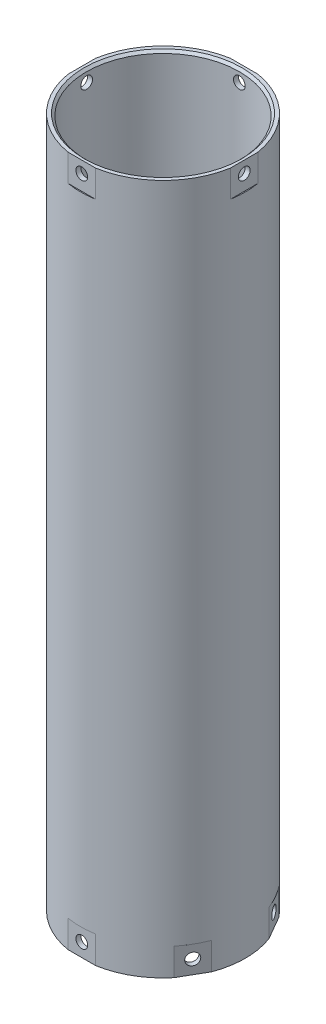
from build123d import *

# Parameters (mm, degrees)
F_1_4_0_25_DIAMETER_HOLE1_REACH  = 380.534
F_1_4_0_25_DIAMETER_HOLE1_BORE_R = 3.175
CIRPATTERN2_COUNT                = 4
CHAMFER1_SIZE                    = 1.27
CIRPATTERN1_COUNT                = 6
SKETCH7_W                        = 14.732
SKETCH7_H                        = 14.732
CUT_EXTRUDE1_DEPTH               = 0.635
SKETCH8_W                        = 16.51
SKETCH8_H                        = 16.51
CUT_EXTRUDE2_DEPTH               = 0.635
CIRPATTERN4_COUNT                = 6
CIRPATTERN5_COUNT                = 4


with BuildPart() as part:
    # Sketch2 → Revolve1 (revolve)
    with BuildSketch(Plane.XY, mode=Mode.PRIVATE) as revolve1_sk:
        Polygon((41.275, 0), (44.45, 0), (44.45, 372.618), (41.275, 372.618), (41.275, 186.309), align=None)
    revolve(revolve1_sk.sketch.rotate(Axis((0, 0, 0), (0, 1, 0)), 90), axis=Axis((0, 0, 0), (0, 1, 0)))

    # 1_4 _0.25_ Diameter Hole1 bore (on position points) → 1_4 _0.25_ Diameter Hole1 (cut, up to next)
    with BuildSketch(Plane(origin=(0, 7.366, -44.45), x_dir=(-1, 0, 0), z_dir=(0, 0, -1)), mode=Mode.PRIVATE) as f_1_4_0_25_diameter_hole1_sk1:
        Circle(F_1_4_0_25_DIAMETER_HOLE1_BORE_R)
    f_1_4_0_25_diameter_hole1_tool1 = extrude(f_1_4_0_25_diameter_hole1_sk1.sketch, amount=-F_1_4_0_25_DIAMETER_HOLE1_REACH, mode=Mode.PRIVATE) & part.part
    f_1_4_0_25_diameter_hole1 = f_1_4_0_25_diameter_hole1_tool1.solids().sort_by_distance((0, 7.366, -44.45))[0]
    add(f_1_4_0_25_diameter_hole1, mode=Mode.SUBTRACT)

    # Sketch6 → 1_4 _0.25_ Diameter Hole2 (revolve, cut)
    with BuildSketch(Plane(origin=(0, 366.268, -44.45), x_dir=(0, 1, 0), z_dir=(1, 0, 0))):
        Polygon((0, 0), (0, 5.209732465), (3.175, 3.302), (3.175, 0), align=None)
    f_1_4_0_25_diameter_hole2 = revolve(axis=Axis((0, 366.268, -50.8), (0, 0, 1)), mode=Mode.SUBTRACT)

    # CirPattern2: 1_4 _0.25_ Diameter Hole2 ×4 about axis
    cirpattern2_axis = Axis((0, -17.04721, 0), (0, 1, 0))
    for i in range(1, CIRPATTERN2_COUNT):
        add(f_1_4_0_25_diameter_hole2.rotate(cirpattern2_axis, i * 360 / CIRPATTERN2_COUNT), mode=Mode.SUBTRACT)

    # Chamfer1
    chamfer1_edges = [part.edges().sort_by_distance(p)[0] for p in [
        (0, 372.618, 41.275),
        (0, 0, 41.275),
    ]]
    chamfer(chamfer1_edges, length=CHAMFER1_SIZE)

    # CirPattern1: 1_4 _0.25_ Diameter Hole1 ×6 about axis
    cirpattern1_axis = Axis((0, -17.04721, 0), (0, 1, 0))
    for i in range(1, CIRPATTERN1_COUNT):
        add(f_1_4_0_25_diameter_hole1.rotate(cirpattern1_axis, i * 360 / CIRPATTERN1_COUNT), mode=Mode.SUBTRACT)

    # Sketch7 → Cut-Extrude1 (cut)
    with BuildSketch(Plane(origin=(0, 0, -44.45), x_dir=(-1, 0, 0), z_dir=(0, 0, -1))):
        with Locations((0, 7.366)):
            Rectangle(SKETCH7_W, SKETCH7_H)
    cut_extrude1 = extrude(amount=-CUT_EXTRUDE1_DEPTH, mode=Mode.SUBTRACT)

    # Sketch8 → Cut-Extrude2 (cut)
    with BuildSketch(Plane(origin=(0, 0, -44.45), x_dir=(-1, 0, 0), z_dir=(0, 0, -1))):
        with Locations((0, 366.268)):
            Rectangle(SKETCH8_W, SKETCH8_H)
    cut_extrude2 = extrude(amount=-CUT_EXTRUDE2_DEPTH, mode=Mode.SUBTRACT)

    # CirPattern4: Cut-Extrude1 ×6 about axis
    cirpattern4_axis = Axis((0, 0, 0), (0, 1, 0))
    for i in range(1, CIRPATTERN4_COUNT):
        add(cut_extrude1.rotate(cirpattern4_axis, i * 360 / CIRPATTERN4_COUNT), mode=Mode.SUBTRACT)

    # CirPattern5: Cut-Extrude2 ×4 about axis
    cirpattern5_axis = Axis((0, 0, 0), (0, 1, 0))
    for i in range(1, CIRPATTERN5_COUNT):
        add(cut_extrude2.rotate(cirpattern5_axis, i * 360 / CIRPATTERN5_COUNT), mode=Mode.SUBTRACT)


solid = part.part
